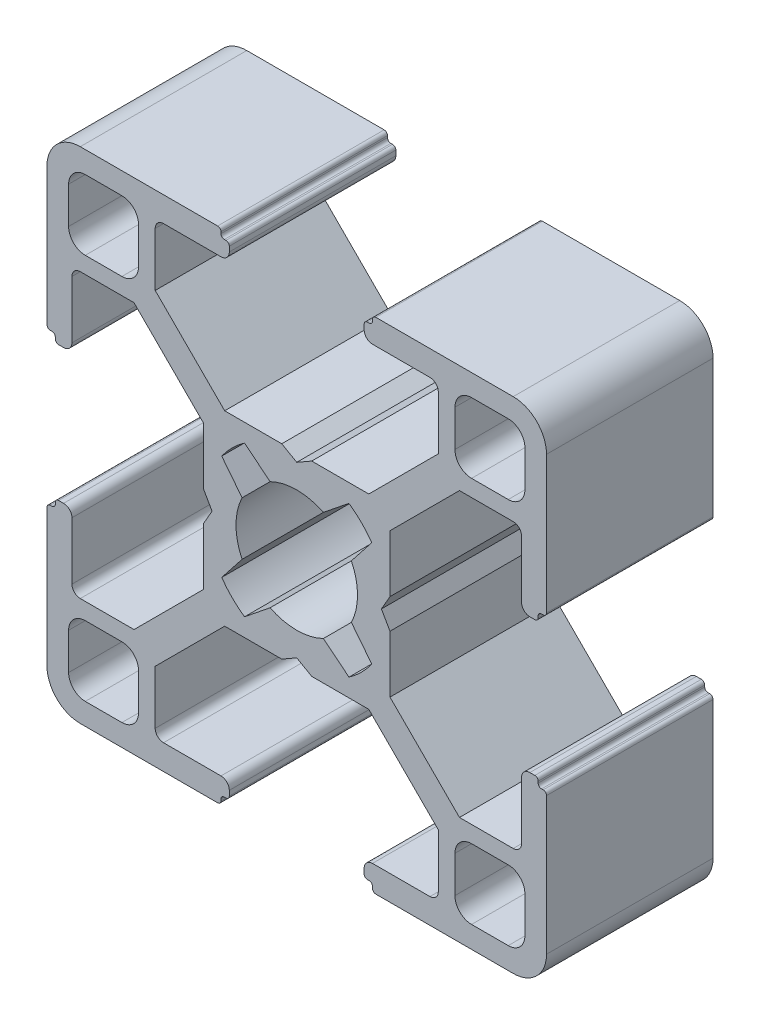
from build123d import *

# Parameters (mm, degrees)
EXTRUDE_1_DEPTH = 10


with BuildPart() as part:
    # Эскиз1 → Бобышка-Вытянуть1 (new body)
    with BuildSketch(Plane.XY):
        with BuildLine():
            Line((-4.05, 14.299999626), (-4.05, 14))
            ThreePointArc((-4.05, 14), (-4.196446609, 13.646446609), (-4.55, 13.5))
            Line((-4.55, 13.5), (-8.000000327, 13.5))
            ThreePointArc((-8.000000327, 13.5), (-8.353553718, 13.353553391), (-8.500000327, 13))
            Line((-8.500000327, 13), (-8.500000327, 9.772792533))
            Line((-8.500000327, 9.772792533), (-4.327207794, 5.6))
            Line((-4.327207794, 5.6), (-0.899999946, 5.6))
            Line((-0.899999946, 5.6), (0, 5.084851837))
            Line((0, 5.084851837), (0.899999946, 5.6))
            Line((0.899999946, 5.6), (4.327207794, 5.6))
            Line((4.327207794, 5.6), (8.500000327, 9.772792533))
            Line((8.500000327, 9.772792533), (8.500000327, 13))
            ThreePointArc((8.500000327, 13), (8.353553718, 13.353553391), (8.000000327, 13.5))
            Line((8.000000327, 13.5), (4.55, 13.5))
            ThreePointArc((4.55, 13.5), (4.196446609, 13.646446609), (4.05, 14))
            Line((4.05, 14), (4.05, 14.299999626))
            ThreePointArc((4.05, 14.299999626), (4.108578753, 14.441421247), (4.250000374, 14.5))
            Line((4.250000374, 14.5), (4.350000144, 14.5))
            ThreePointArc((4.350000144, 14.5), (4.49142109, 14.558578474), (4.549999564, 14.69999942))
            Line((4.549999564, 14.69999942), (4.549999564, 14.799999619))
            ThreePointArc((4.549999564, 14.799999619), (4.60857832, 14.941421245), (4.749999945, 15))
            Line((4.749999945, 15), (13.000000346, 15))
            ThreePointArc((13.000000346, 15), (14.414213664, 14.414213664), (15, 13.000000346))
            Line((15, 13.000000346), (15, 4.749999945))
            ThreePointArc((15, 4.749999945), (14.941421245, 4.60857832), (14.799999619, 4.549999564))
            Line((14.799999619, 4.549999564), (14.69999942, 4.549999564))
            ThreePointArc((14.69999942, 4.549999564), (14.558578474, 4.49142109), (14.5, 4.350000144))
            Line((14.5, 4.350000144), (14.5, 4.250000374))
            ThreePointArc((14.5, 4.250000374), (14.441421247, 4.108578753), (14.299999626, 4.05))
            Line((14.299999626, 4.05), (14, 4.05))
            ThreePointArc((14, 4.05), (13.646446609, 4.196446609), (13.5, 4.55))
            Line((13.5, 4.55), (13.5, 8.000000327))
            ThreePointArc((13.5, 8.000000327), (13.353553391, 8.353553718), (13, 8.500000327))
            Line((13, 8.500000327), (9.772792533, 8.500000327))
            Line((9.772792533, 8.500000327), (5.6, 4.327207794))
            Line((5.6, 4.327207794), (5.6, 0.899999946))
            Line((5.6, 0.899999946), (5.084851837, 0))
            Line((5.084851837, 0), (5.6, -0.899999946))
            Line((5.6, -0.899999946), (5.6, -4.327207794))
            Line((5.6, -4.327207794), (9.772792533, -8.500000327))
            Line((9.772792533, -8.500000327), (13, -8.500000327))
            ThreePointArc((13, -8.500000327), (13.353553391, -8.353553718), (13.5, -8.000000327))
            Line((13.5, -8.000000327), (13.5, -4.55))
            ThreePointArc((13.5, -4.55), (13.646446609, -4.196446609), (14, -4.05))
            Line((14, -4.05), (14.299999626, -4.05))
            ThreePointArc((14.299999626, -4.05), (14.441421247, -4.108578753), (14.5, -4.250000374))
            Line((14.5, -4.250000374), (14.5, -4.350000144))
            ThreePointArc((14.5, -4.350000144), (14.558578474, -4.49142109), (14.69999942, -4.549999564))
            Line((14.69999942, -4.549999564), (14.799999619, -4.549999564))
            ThreePointArc((14.799999619, -4.549999564), (14.941421245, -4.60857832), (15, -4.749999945))
            Line((15, -4.749999945), (15, -13.000000346))
            ThreePointArc((15, -13.000000346), (14.414213664, -14.414213664), (13.000000346, -15))
            Line((13.000000346, -15), (4.749999945, -15))
            ThreePointArc((4.749999945, -15), (4.60857832, -14.941421245), (4.549999564, -14.799999619))
            Line((4.549999564, -14.799999619), (4.549999564, -14.69999942))
            ThreePointArc((4.549999564, -14.69999942), (4.49142109, -14.558578474), (4.350000144, -14.5))
            Line((4.350000144, -14.5), (4.250000374, -14.5))
            ThreePointArc((4.250000374, -14.5), (4.108578753, -14.441421247), (4.05, -14.299999626))
            Line((4.05, -14.299999626), (4.05, -14))
            ThreePointArc((4.05, -14), (4.196446609, -13.646446609), (4.55, -13.5))
            Line((4.55, -13.5), (8.000000327, -13.5))
            ThreePointArc((8.000000327, -13.5), (8.353553718, -13.353553391), (8.500000327, -13))
            Line((8.500000327, -13), (8.500000327, -9.772792533))
            Line((8.500000327, -9.772792533), (4.327207794, -5.6))
            Line((4.327207794, -5.6), (0.899999946, -5.6))
            Line((0.899999946, -5.6), (0, -5.084851837))
            Line((0, -5.084851837), (-0.899999946, -5.6))
            Line((-0.899999946, -5.6), (-4.327207794, -5.6))
            Line((-4.327207794, -5.6), (-8.500000327, -9.772792533))
            Line((-8.500000327, -9.772792533), (-8.500000327, -13))
            ThreePointArc((-8.500000327, -13), (-8.353553718, -13.353553391), (-8.000000327, -13.5))
            Line((-8.000000327, -13.5), (-4.55, -13.5))
            ThreePointArc((-4.55, -13.5), (-4.196446609, -13.646446609), (-4.05, -14))
            Line((-4.05, -14), (-4.05, -14.299999626))
            ThreePointArc((-4.05, -14.299999626), (-4.108578753, -14.441421247), (-4.250000374, -14.5))
            Line((-4.250000374, -14.5), (-4.350000144, -14.5))
            ThreePointArc((-4.350000144, -14.5), (-4.49142109, -14.558578474), (-4.549999564, -14.69999942))
            Line((-4.549999564, -14.69999942), (-4.549999564, -14.799999619))
            ThreePointArc((-4.549999564, -14.799999619), (-4.60857832, -14.941421245), (-4.749999945, -15))
            Line((-4.749999945, -15), (-13.000000346, -15))
            ThreePointArc((-13.000000346, -15), (-14.414213664, -14.414213664), (-15, -13.000000346))
            Line((-15, -13.000000346), (-15, -4.749999945))
            ThreePointArc((-15, -4.749999945), (-14.941421245, -4.60857832), (-14.799999619, -4.549999564))
            Line((-14.799999619, -4.549999564), (-14.69999942, -4.549999564))
            ThreePointArc((-14.69999942, -4.549999564), (-14.558578474, -4.49142109), (-14.5, -4.350000144))
            Line((-14.5, -4.350000144), (-14.5, -4.250000374))
            ThreePointArc((-14.5, -4.250000374), (-14.441421247, -4.108578753), (-14.299999626, -4.05))
            Line((-14.299999626, -4.05), (-14, -4.05))
            ThreePointArc((-14, -4.05), (-13.646446609, -4.196446609), (-13.5, -4.55))
            Line((-13.5, -4.55), (-13.5, -8.000000327))
            ThreePointArc((-13.5, -8.000000327), (-13.353553391, -8.353553718), (-13, -8.500000327))
            Line((-13, -8.500000327), (-9.772792533, -8.500000327))
            Line((-9.772792533, -8.500000327), (-5.6, -4.327207794))
            Line((-5.6, -4.327207794), (-5.6, -0.899999946))
            Line((-5.6, -0.899999946), (-5.084851837, 0))
            Line((-5.084851837, 0), (-5.6, 0.899999946))
            Line((-5.6, 0.899999946), (-5.6, 4.327207794))
            Line((-5.6, 4.327207794), (-9.772792533, 8.500000327))
            Line((-9.772792533, 8.500000327), (-13, 8.500000327))
            ThreePointArc((-13, 8.500000327), (-13.353553391, 8.353553718), (-13.5, 8.000000327))
            Line((-13.5, 8.000000327), (-13.5, 4.55))
            ThreePointArc((-13.5, 4.55), (-13.646446609, 4.196446609), (-14, 4.05))
            Line((-14, 4.05), (-14.299999626, 4.05))
            ThreePointArc((-14.299999626, 4.05), (-14.441421247, 4.108578753), (-14.5, 4.250000374))
            Line((-14.5, 4.250000374), (-14.5, 4.350000144))
            ThreePointArc((-14.5, 4.350000144), (-14.558578474, 4.49142109), (-14.69999942, 4.549999564))
            Line((-14.69999942, 4.549999564), (-14.799999619, 4.549999564))
            ThreePointArc((-14.799999619, 4.549999564), (-14.941421245, 4.60857832), (-15, 4.749999945))
            Line((-15, 4.749999945), (-15, 13.000000346))
            ThreePointArc((-15, 13.000000346), (-14.414213664, 14.414213664), (-13.000000346, 15))
            Line((-13.000000346, 15), (-4.749999945, 15))
            ThreePointArc((-4.749999945, 15), (-4.60857832, 14.941421245), (-4.549999564, 14.799999619))
            Line((-4.549999564, 14.799999619), (-4.549999564, 14.69999942))
            ThreePointArc((-4.549999564, 14.69999942), (-4.49142109, 14.558578474), (-4.350000144, 14.5))
            Line((-4.350000144, 14.5), (-4.250000374, 14.5))
            ThreePointArc((-4.250000374, 14.5), (-4.108578753, 14.441421247), (-4.05, 14.299999626))
        make_face()
        with BuildLine():
            Line((-3.280561732, 1.600129597), (-4.505336892, 3.154669473))
            ThreePointArc((-4.505336892, 3.154669473), (-3.881002259, 3.897155561), (-3.135929412, 4.518400903))
            Line((-3.135929412, 4.518400903), (-1.600129524, 3.280561767))
            ThreePointArc((-1.600129524, 3.280561767), (0, 3.65), (1.600129524, 3.280561767))
            Line((1.600129524, 3.280561767), (3.135929412, 4.518400903))
            ThreePointArc((3.135929412, 4.518400903), (3.881002259, 3.897155561), (4.505336892, 3.154669473))
            Line((4.505336892, 3.154669473), (3.280561732, 1.600129597))
            ThreePointArc((3.280561732, 1.600129597), (3.65, 0), (3.280561732, -1.600129597))
            Line((3.280561732, -1.600129597), (4.505336892, -3.154669473))
            ThreePointArc((4.505336892, -3.154669473), (3.881002259, -3.897155561), (3.135929412, -4.518400903))
            Line((3.135929412, -4.518400903), (1.600129524, -3.280561767))
            ThreePointArc((1.600129524, -3.280561767), (0, -3.65), (-1.600129524, -3.280561767))
            Line((-1.600129524, -3.280561767), (-3.135929412, -4.518400903))
            ThreePointArc((-3.135929412, -4.518400903), (-3.881002259, -3.897155561), (-4.505336892, -3.154669473))
            Line((-4.505336892, -3.154669473), (-3.280561732, -1.600129597))
            ThreePointArc((-3.280561732, -1.600129597), (-3.65, 0), (-3.280561732, 1.600129597))
        make_face(mode=Mode.SUBTRACT)
        with BuildLine():
            Line((-10.500000327, 13.700000398), (-12.7000011, 13.700000398))
            ThreePointArc((-12.7000011, 13.700000398), (-13.407107877, 13.407107179), (-13.70000109, 12.700000398))
            Line((-13.70000109, 12.700000398), (-13.70000109, 10.499999635))
            ThreePointArc((-13.70000109, 10.499999635), (-13.407107874, 9.792892851), (-12.70000109, 9.499999635))
            Line((-12.70000109, 9.499999635), (-10.500000327, 9.499999635))
            ThreePointArc((-10.500000327, 9.499999635), (-9.792893543, 9.792892851), (-9.500000327, 10.499999635))
            Line((-9.500000327, 10.499999635), (-9.500000327, 12.700000398))
            ThreePointArc((-9.500000327, 12.700000398), (-9.792893543, 13.407107182), (-10.500000327, 13.700000398))
        make_face(mode=Mode.SUBTRACT)
        with BuildLine():
            Line((13.70000109, 12.700000398), (13.70000109, 10.499999635))
            ThreePointArc((13.70000109, 10.499999635), (13.407107874, 9.792892851), (12.70000109, 9.499999635))
            Line((12.70000109, 9.499999635), (10.500000327, 9.499999635))
            ThreePointArc((10.500000327, 9.499999635), (9.792893543, 9.792892851), (9.500000327, 10.499999635))
            Line((9.500000327, 10.499999635), (9.500000327, 12.700000398))
            ThreePointArc((9.500000327, 12.700000398), (9.792893543, 13.407107182), (10.500000327, 13.700000398))
            Line((10.500000327, 13.700000398), (12.7000011, 13.700000398))
            ThreePointArc((12.7000011, 13.700000398), (13.407107877, 13.407107179), (13.70000109, 12.700000398))
        make_face(mode=Mode.SUBTRACT)
        with BuildLine():
            Line((10.500000327, -13.700000398), (12.7000011, -13.700000398))
            ThreePointArc((12.7000011, -13.700000398), (13.407107877, -13.407107179), (13.70000109, -12.700000398))
            Line((13.70000109, -12.700000398), (13.70000109, -10.499999635))
            ThreePointArc((13.70000109, -10.499999635), (13.407107874, -9.792892851), (12.70000109, -9.499999635))
            Line((12.70000109, -9.499999635), (10.500000327, -9.499999635))
            ThreePointArc((10.500000327, -9.499999635), (9.792893543, -9.792892851), (9.500000327, -10.499999635))
            Line((9.500000327, -10.499999635), (9.500000327, -12.700000398))
            ThreePointArc((9.500000327, -12.700000398), (9.792893543, -13.407107182), (10.500000327, -13.700000398))
        make_face(mode=Mode.SUBTRACT)
        with BuildLine():
            Line((-13.70000109, -12.700000398), (-13.70000109, -10.499999635))
            ThreePointArc((-13.70000109, -10.499999635), (-13.407107874, -9.792892851), (-12.70000109, -9.499999635))
            Line((-12.70000109, -9.499999635), (-10.500000327, -9.499999635))
            ThreePointArc((-10.500000327, -9.499999635), (-9.792893543, -9.792892851), (-9.500000327, -10.499999635))
            Line((-9.500000327, -10.499999635), (-9.500000327, -12.700000398))
            ThreePointArc((-9.500000327, -12.700000398), (-9.792893543, -13.407107182), (-10.500000327, -13.700000398))
            Line((-10.500000327, -13.700000398), (-12.7000011, -13.700000398))
            ThreePointArc((-12.7000011, -13.700000398), (-13.407107877, -13.407107179), (-13.70000109, -12.700000398))
        make_face(mode=Mode.SUBTRACT)
    extrude(amount=EXTRUDE_1_DEPTH)


solid = part.part
